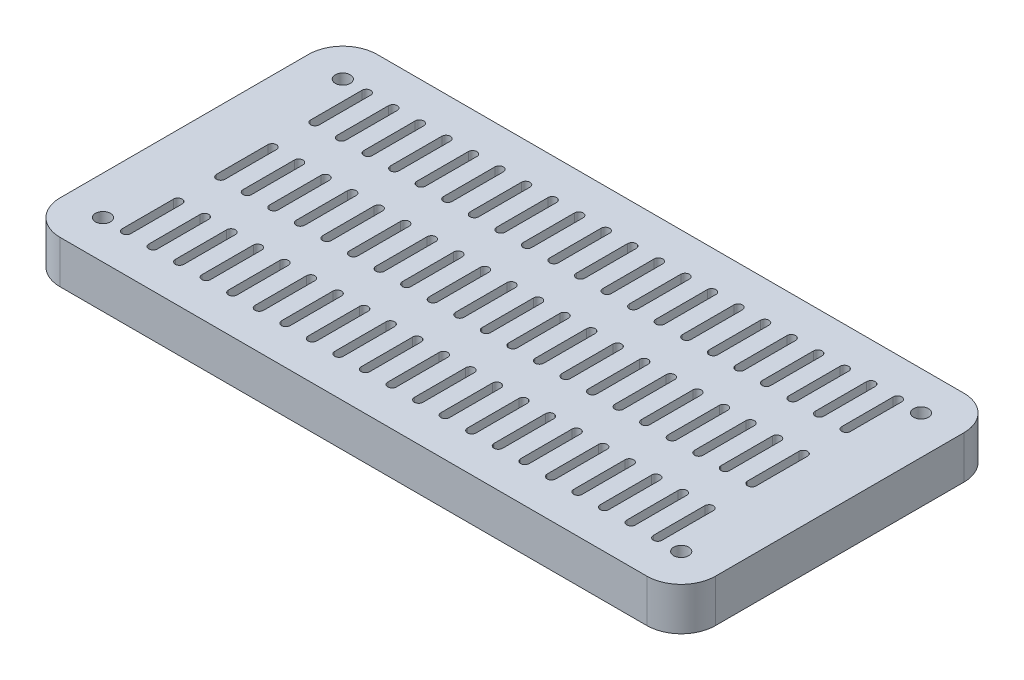
from build123d import *

# Parameters (mm, degrees)
SKETCH1_W               = 153
SKETCH1_H               = 74
BOSS_EXTRUDE1_DEPTH     = 10
CUT_EXTRUDE1_DEPTH      = 11
LPATTERN1_COUNT         = 11
LPATTERN1_PITCH         = 6.2
LPATTERN1_COUNT_DIR2    = 2
LPATTERN1_PITCH_DIR2    = 22
SKETCH3_R               = 1.75
CUT_EXTRUDE2_DEPTH      = 11
MIRROR1_COPY_1_DEPTH    = 11
MIRROR1_COPY_2_DEPTH    = 11
MIRROR1_COPY_3_DEPTH    = 11
MIRROR1_COPY_4_DEPTH    = 11
MIRROR1_COPY_5_DEPTH    = 11
MIRROR1_COPY_6_DEPTH    = 11
MIRROR1_COPY_7_DEPTH    = 11
MIRROR1_COPY_8_DEPTH    = 11
MIRROR1_COPY_9_DEPTH    = 11
MIRROR1_COPY_10_DEPTH   = 11
MIRROR1_COPY_11_DEPTH   = 11
MIRROR1_COPY_12_DEPTH   = 11
MIRROR1_COPY_13_DEPTH   = 11
MIRROR1_COPY_14_DEPTH   = 11
MIRROR1_COPY_15_DEPTH   = 11
MIRROR1_COPY_16_DEPTH   = 11
MIRROR1_COPY_17_DEPTH   = 11
MIRROR1_COPY_18_DEPTH   = 11
MIRROR1_COPY_19_DEPTH   = 11
MIRROR1_COPY_20_DEPTH   = 11
MIRROR1_COPY_21_DEPTH   = 11
MIRROR1_COPY_22_DEPTH   = 11
MIRROR2_COPY_1_SKETCH_R = 1.75
MIRROR2_COPY_1_DEPTH    = 11
MIRROR2_COPY_2_DEPTH    = 11
MIRROR2_COPY_3_DEPTH    = 11
MIRROR2_COPY_4_DEPTH    = 11
MIRROR2_COPY_5_DEPTH    = 11
MIRROR2_COPY_6_DEPTH    = 11
MIRROR2_COPY_7_DEPTH    = 11
MIRROR2_COPY_8_DEPTH    = 11
MIRROR2_COPY_9_DEPTH    = 11
MIRROR2_COPY_10_DEPTH   = 11
MIRROR2_COPY_11_DEPTH   = 11
MIRROR2_COPY_12_DEPTH   = 11
MIRROR2_COPY_13_DEPTH   = 11
MIRROR2_COPY_14_DEPTH   = 11
MIRROR2_COPY_15_DEPTH   = 11
MIRROR2_COPY_16_DEPTH   = 11
MIRROR2_COPY_17_DEPTH   = 11
MIRROR2_COPY_18_DEPTH   = 11
MIRROR2_COPY_19_DEPTH   = 11
MIRROR2_COPY_20_DEPTH   = 11
MIRROR2_COPY_21_DEPTH   = 11
MIRROR2_COPY_22_DEPTH   = 11
MIRROR2_COPY_23_DEPTH   = 11
MIRROR2_COPY_24_DEPTH   = 11
MIRROR2_COPY_25_DEPTH   = 11
MIRROR2_COPY_26_DEPTH   = 11
MIRROR2_COPY_27_DEPTH   = 11
MIRROR2_COPY_28_DEPTH   = 11
MIRROR2_COPY_29_DEPTH   = 11
MIRROR2_COPY_30_DEPTH   = 11
MIRROR2_COPY_31_DEPTH   = 11
MIRROR2_COPY_32_DEPTH   = 11
MIRROR2_COPY_33_DEPTH   = 11
MIRROR2_COPY_34_DEPTH   = 11
MIRROR2_COPY_35_DEPTH   = 11
MIRROR2_COPY_36_DEPTH   = 11
MIRROR2_COPY_37_DEPTH   = 11
MIRROR2_COPY_38_DEPTH   = 11
MIRROR2_COPY_39_DEPTH   = 11
MIRROR2_COPY_40_DEPTH   = 11
MIRROR2_COPY_41_DEPTH   = 11
MIRROR2_COPY_42_DEPTH   = 11
MIRROR2_COPY_43_DEPTH   = 11
MIRROR2_COPY_44_DEPTH   = 11
MIRROR2_COPY_45_DEPTH   = 11
MIRROR2_COPY_46_DEPTH   = 11
FILLET1_R               = 8


with BuildPart() as part:
    # Sketch1 → Boss-Extrude1 (new body)
    with BuildSketch(Plane(origin=(0, 0, 0), x_dir=(1, 0, 0), z_dir=(0, 1, 0))):
        Rectangle(SKETCH1_W, SKETCH1_H)
        with BuildLine():
            ThreePointArc((39.5, -27), (66.5, 0), (39.5, 27))
            Line((39.5, 27), (-39.5, 27))
            ThreePointArc((-39.5, 27), (-66.5, 0), (-39.5, -27))
            Line((-39.5, -27), (39.5, -27))
        make_face(mode=Mode.SUBTRACT)
        with BuildLine():
            Line((-39.5, -27), (39.5, -27))
            ThreePointArc((39.5, -27), (66.5, 0), (39.5, 27))
            Line((39.5, 27), (-39.5, 27))
            ThreePointArc((-39.5, 27), (-66.5, 0), (-39.5, -27))
        make_face()
        with BuildLine():
            ThreePointArc((1, 6), (0, 7), (-1, 6))
            Line((-1, 6), (-1, -6))
            ThreePointArc((-1, -6), (0, -7), (1, -6))
            Line((1, -6), (1, 6))
        make_face(mode=Mode.SUBTRACT)
        with BuildLine():
            Line((1, -6), (1, 6))
            ThreePointArc((1, 6), (0, 7), (-1, 6))
            Line((-1, 6), (-1, -6))
            ThreePointArc((-1, -6), (0, -7), (1, -6))
        make_face()
    extrude(amount=BOSS_EXTRUDE1_DEPTH)

    # Sketch1_3 → Cut-Extrude1 (cut, through all)
    with BuildSketch(Plane(origin=(0, 0, 0), x_dir=(1, 0, 0), z_dir=(0, 1, 0))):
        with BuildLine():
            Line((1, -6), (1, 6))
            ThreePointArc((1, 6), (0, 7), (-1, 6))
            Line((-1, 6), (-1, -6))
            ThreePointArc((-1, -6), (0, -7), (1, -6))
        make_face()
    cut_extrude1 = extrude(amount=CUT_EXTRUDE1_DEPTH, mode=Mode.SUBTRACT)

    # LPattern1: Cut-Extrude1 11 × 2
    with Locations(*[(i * LPATTERN1_PITCH, 0, -j * LPATTERN1_PITCH_DIR2) for i in range(LPATTERN1_COUNT) for j in range(LPATTERN1_COUNT_DIR2) if (i, j) != (0, 0)]):
        add(cut_extrude1, mode=Mode.SUBTRACT)

    # Sketch3 → Cut-Extrude2 (cut, through all)
    with BuildSketch(Plane(origin=(0, 10, 0), x_dir=(1, 0, 0), z_dir=(0, 1, 0))):
        with Locations((67.5, 28)):
            Circle(SKETCH3_R)
    cut_extrude2 = extrude(amount=-CUT_EXTRUDE2_DEPTH, mode=Mode.SUBTRACT)

    # Mirror1: Cut-Extrude2 across plane
    add(cut_extrude2.mirror(Plane(origin=(0, 0, 0), x_dir=(0, 0, 1), z_dir=(1, 0, 0))), mode=Mode.SUBTRACT)

    # Mirror1 copy 1 sketch → Mirror1 copy 1 (cut, through all)
    with BuildSketch(Plane(origin=(0, 0, -22), x_dir=(-1, 0, 0), z_dir=(0, 1, 0))):
        with BuildLine():
            Line((1, 6), (1, -6))
            ThreePointArc((1, -6), (0, -7), (-1, -6))
            Line((-1, -6), (-1, 6))
            ThreePointArc((-1, 6), (0, 7), (1, 6))
        make_face()
    extrude(amount=MIRROR1_COPY_1_DEPTH, mode=Mode.SUBTRACT)

    # Mirror1 copy 2 sketch → Mirror1 copy 2 (cut, through all)
    with BuildSketch(Plane(origin=(-6.2, 0, 0), x_dir=(-1, 0, 0), z_dir=(0, 1, 0))):
        with BuildLine():
            Line((1, 6), (1, -6))
            ThreePointArc((1, -6), (0, -7), (-1, -6))
            Line((-1, -6), (-1, 6))
            ThreePointArc((-1, 6), (0, 7), (1, 6))
        make_face()
    extrude(amount=MIRROR1_COPY_2_DEPTH, mode=Mode.SUBTRACT)

    # Mirror1 copy 3 sketch → Mirror1 copy 3 (cut, through all)
    with BuildSketch(Plane(origin=(-6.2, 0, -22), x_dir=(-1, 0, 0), z_dir=(0, 1, 0))):
        with BuildLine():
            Line((1, 6), (1, -6))
            ThreePointArc((1, -6), (0, -7), (-1, -6))
            Line((-1, -6), (-1, 6))
            ThreePointArc((-1, 6), (0, 7), (1, 6))
        make_face()
    extrude(amount=MIRROR1_COPY_3_DEPTH, mode=Mode.SUBTRACT)

    # Mirror1 copy 4 sketch → Mirror1 copy 4 (cut, through all)
    with BuildSketch(Plane(origin=(-12.4, 0, 0), x_dir=(-1, 0, 0), z_dir=(0, 1, 0))):
        with BuildLine():
            Line((1, 6), (1, -6))
            ThreePointArc((1, -6), (0, -7), (-1, -6))
            Line((-1, -6), (-1, 6))
            ThreePointArc((-1, 6), (0, 7), (1, 6))
        make_face()
    extrude(amount=MIRROR1_COPY_4_DEPTH, mode=Mode.SUBTRACT)

    # Mirror1 copy 5 sketch → Mirror1 copy 5 (cut, through all)
    with BuildSketch(Plane(origin=(-12.4, 0, -22), x_dir=(-1, 0, 0), z_dir=(0, 1, 0))):
        with BuildLine():
            Line((1, 6), (1, -6))
            ThreePointArc((1, -6), (0, -7), (-1, -6))
            Line((-1, -6), (-1, 6))
            ThreePointArc((-1, 6), (0, 7), (1, 6))
        make_face()
    extrude(amount=MIRROR1_COPY_5_DEPTH, mode=Mode.SUBTRACT)

    # Mirror1 copy 6 sketch → Mirror1 copy 6 (cut, through all)
    with BuildSketch(Plane(origin=(-18.6, 0, 0), x_dir=(-1, 0, 0), z_dir=(0, 1, 0))):
        with BuildLine():
            Line((1, 6), (1, -6))
            ThreePointArc((1, -6), (0, -7), (-1, -6))
            Line((-1, -6), (-1, 6))
            ThreePointArc((-1, 6), (0, 7), (1, 6))
        make_face()
    extrude(amount=MIRROR1_COPY_6_DEPTH, mode=Mode.SUBTRACT)

    # Mirror1 copy 7 sketch → Mirror1 copy 7 (cut, through all)
    with BuildSketch(Plane(origin=(-18.6, 0, -22), x_dir=(-1, 0, 0), z_dir=(0, 1, 0))):
        with BuildLine():
            Line((1, 6), (1, -6))
            ThreePointArc((1, -6), (0, -7), (-1, -6))
            Line((-1, -6), (-1, 6))
            ThreePointArc((-1, 6), (0, 7), (1, 6))
        make_face()
    extrude(amount=MIRROR1_COPY_7_DEPTH, mode=Mode.SUBTRACT)

    # Mirror1 copy 8 sketch → Mirror1 copy 8 (cut, through all)
    with BuildSketch(Plane(origin=(-24.8, 0, 0), x_dir=(-1, 0, 0), z_dir=(0, 1, 0))):
        with BuildLine():
            Line((1, 6), (1, -6))
            ThreePointArc((1, -6), (0, -7), (-1, -6))
            Line((-1, -6), (-1, 6))
            ThreePointArc((-1, 6), (0, 7), (1, 6))
        make_face()
    extrude(amount=MIRROR1_COPY_8_DEPTH, mode=Mode.SUBTRACT)

    # Mirror1 copy 9 sketch → Mirror1 copy 9 (cut, through all)
    with BuildSketch(Plane(origin=(-24.8, 0, -22), x_dir=(-1, 0, 0), z_dir=(0, 1, 0))):
        with BuildLine():
            Line((1, 6), (1, -6))
            ThreePointArc((1, -6), (0, -7), (-1, -6))
            Line((-1, -6), (-1, 6))
            ThreePointArc((-1, 6), (0, 7), (1, 6))
        make_face()
    extrude(amount=MIRROR1_COPY_9_DEPTH, mode=Mode.SUBTRACT)

    # Mirror1 copy 10 sketch → Mirror1 copy 10 (cut, through all)
    with BuildSketch(Plane(origin=(-31, 0, 0), x_dir=(-1, 0, 0), z_dir=(0, 1, 0))):
        with BuildLine():
            Line((1, 6), (1, -6))
            ThreePointArc((1, -6), (0, -7), (-1, -6))
            Line((-1, -6), (-1, 6))
            ThreePointArc((-1, 6), (0, 7), (1, 6))
        make_face()
    extrude(amount=MIRROR1_COPY_10_DEPTH, mode=Mode.SUBTRACT)

    # Mirror1 copy 11 sketch → Mirror1 copy 11 (cut, through all)
    with BuildSketch(Plane(origin=(-31, 0, -22), x_dir=(-1, 0, 0), z_dir=(0, 1, 0))):
        with BuildLine():
            Line((1, 6), (1, -6))
            ThreePointArc((1, -6), (0, -7), (-1, -6))
            Line((-1, -6), (-1, 6))
            ThreePointArc((-1, 6), (0, 7), (1, 6))
        make_face()
    extrude(amount=MIRROR1_COPY_11_DEPTH, mode=Mode.SUBTRACT)

    # Mirror1 copy 12 sketch → Mirror1 copy 12 (cut, through all)
    with BuildSketch(Plane(origin=(-37.2, 0, 0), x_dir=(-1, 0, 0), z_dir=(0, 1, 0))):
        with BuildLine():
            Line((1, 6), (1, -6))
            ThreePointArc((1, -6), (0, -7), (-1, -6))
            Line((-1, -6), (-1, 6))
            ThreePointArc((-1, 6), (0, 7), (1, 6))
        make_face()
    extrude(amount=MIRROR1_COPY_12_DEPTH, mode=Mode.SUBTRACT)

    # Mirror1 copy 13 sketch → Mirror1 copy 13 (cut, through all)
    with BuildSketch(Plane(origin=(-37.2, 0, -22), x_dir=(-1, 0, 0), z_dir=(0, 1, 0))):
        with BuildLine():
            Line((1, 6), (1, -6))
            ThreePointArc((1, -6), (0, -7), (-1, -6))
            Line((-1, -6), (-1, 6))
            ThreePointArc((-1, 6), (0, 7), (1, 6))
        make_face()
    extrude(amount=MIRROR1_COPY_13_DEPTH, mode=Mode.SUBTRACT)

    # Mirror1 copy 14 sketch → Mirror1 copy 14 (cut, through all)
    with BuildSketch(Plane(origin=(-43.4, 0, 0), x_dir=(-1, 0, 0), z_dir=(0, 1, 0))):
        with BuildLine():
            Line((1, 6), (1, -6))
            ThreePointArc((1, -6), (0, -7), (-1, -6))
            Line((-1, -6), (-1, 6))
            ThreePointArc((-1, 6), (0, 7), (1, 6))
        make_face()
    extrude(amount=MIRROR1_COPY_14_DEPTH, mode=Mode.SUBTRACT)

    # Mirror1 copy 15 sketch → Mirror1 copy 15 (cut, through all)
    with BuildSketch(Plane(origin=(-43.4, 0, -22), x_dir=(-1, 0, 0), z_dir=(0, 1, 0))):
        with BuildLine():
            Line((1, 6), (1, -6))
            ThreePointArc((1, -6), (0, -7), (-1, -6))
            Line((-1, -6), (-1, 6))
            ThreePointArc((-1, 6), (0, 7), (1, 6))
        make_face()
    extrude(amount=MIRROR1_COPY_15_DEPTH, mode=Mode.SUBTRACT)

    # Mirror1 copy 16 sketch → Mirror1 copy 16 (cut, through all)
    with BuildSketch(Plane(origin=(-49.6, 0, 0), x_dir=(-1, 0, 0), z_dir=(0, 1, 0))):
        with BuildLine():
            Line((1, 6), (1, -6))
            ThreePointArc((1, -6), (0, -7), (-1, -6))
            Line((-1, -6), (-1, 6))
            ThreePointArc((-1, 6), (0, 7), (1, 6))
        make_face()
    extrude(amount=MIRROR1_COPY_16_DEPTH, mode=Mode.SUBTRACT)

    # Mirror1 copy 17 sketch → Mirror1 copy 17 (cut, through all)
    with BuildSketch(Plane(origin=(-49.6, 0, -22), x_dir=(-1, 0, 0), z_dir=(0, 1, 0))):
        with BuildLine():
            Line((1, 6), (1, -6))
            ThreePointArc((1, -6), (0, -7), (-1, -6))
            Line((-1, -6), (-1, 6))
            ThreePointArc((-1, 6), (0, 7), (1, 6))
        make_face()
    extrude(amount=MIRROR1_COPY_17_DEPTH, mode=Mode.SUBTRACT)

    # Mirror1 copy 18 sketch → Mirror1 copy 18 (cut, through all)
    with BuildSketch(Plane(origin=(-55.8, 0, 0), x_dir=(-1, 0, 0), z_dir=(0, 1, 0))):
        with BuildLine():
            Line((1, 6), (1, -6))
            ThreePointArc((1, -6), (0, -7), (-1, -6))
            Line((-1, -6), (-1, 6))
            ThreePointArc((-1, 6), (0, 7), (1, 6))
        make_face()
    extrude(amount=MIRROR1_COPY_18_DEPTH, mode=Mode.SUBTRACT)

    # Mirror1 copy 19 sketch → Mirror1 copy 19 (cut, through all)
    with BuildSketch(Plane(origin=(-55.8, 0, -22), x_dir=(-1, 0, 0), z_dir=(0, 1, 0))):
        with BuildLine():
            Line((1, 6), (1, -6))
            ThreePointArc((1, -6), (0, -7), (-1, -6))
            Line((-1, -6), (-1, 6))
            ThreePointArc((-1, 6), (0, 7), (1, 6))
        make_face()
    extrude(amount=MIRROR1_COPY_19_DEPTH, mode=Mode.SUBTRACT)

    # Mirror1 copy 20 sketch → Mirror1 copy 20 (cut, through all)
    with BuildSketch(Plane(origin=(-62, 0, 0), x_dir=(-1, 0, 0), z_dir=(0, 1, 0))):
        with BuildLine():
            Line((1, 6), (1, -6))
            ThreePointArc((1, -6), (0, -7), (-1, -6))
            Line((-1, -6), (-1, 6))
            ThreePointArc((-1, 6), (0, 7), (1, 6))
        make_face()
    extrude(amount=MIRROR1_COPY_20_DEPTH, mode=Mode.SUBTRACT)

    # Mirror1 copy 21 sketch → Mirror1 copy 21 (cut, through all)
    with BuildSketch(Plane(origin=(-62, 0, -22), x_dir=(-1, 0, 0), z_dir=(0, 1, 0))):
        with BuildLine():
            Line((1, 6), (1, -6))
            ThreePointArc((1, -6), (0, -7), (-1, -6))
            Line((-1, -6), (-1, 6))
            ThreePointArc((-1, 6), (0, 7), (1, 6))
        make_face()
    extrude(amount=MIRROR1_COPY_21_DEPTH, mode=Mode.SUBTRACT)

    # Mirror1 copy 22 sketch → Mirror1 copy 22 (cut, through all)
    with BuildSketch(Plane(origin=(0, 0, 0), x_dir=(-1, 0, 0), z_dir=(0, 1, 0))):
        with BuildLine():
            Line((1, 6), (1, -6))
            ThreePointArc((1, -6), (0, -7), (-1, -6))
            Line((-1, -6), (-1, 6))
            ThreePointArc((-1, 6), (0, 7), (1, 6))
        make_face()
    extrude(amount=MIRROR1_COPY_22_DEPTH, mode=Mode.SUBTRACT)

    # Mirror2: Cut-Extrude2 across plane
    add(cut_extrude2.mirror(Plane.XY), mode=Mode.SUBTRACT)

    # Mirror2 copy 1 sketch → Mirror2 copy 1 (cut, through all)
    with BuildSketch(Plane(origin=(0, 10, 0), x_dir=(-1, 0, 0), z_dir=(0, 1, 0))):
        with Locations((67.5, 28)):
            Circle(MIRROR2_COPY_1_SKETCH_R)
    extrude(amount=-MIRROR2_COPY_1_DEPTH, mode=Mode.SUBTRACT)

    # Mirror2 copy 2 sketch → Mirror2 copy 2 (cut, through all)
    with BuildSketch(Plane(origin=(0, 0, 22), x_dir=(-1, 0, 0), z_dir=(0, 1, 0))):
        with BuildLine():
            Line((1, -6), (1, 6))
            ThreePointArc((1, 6), (0, 7), (-1, 6))
            Line((-1, 6), (-1, -6))
            ThreePointArc((-1, -6), (0, -7), (1, -6))
        make_face()
    extrude(amount=MIRROR2_COPY_2_DEPTH, mode=Mode.SUBTRACT)

    # Mirror2 copy 3 sketch → Mirror2 copy 3 (cut, through all)
    with BuildSketch(Plane(origin=(-6.2, 0, 0), x_dir=(-1, 0, 0), z_dir=(0, 1, 0))):
        with BuildLine():
            Line((1, -6), (1, 6))
            ThreePointArc((1, 6), (0, 7), (-1, 6))
            Line((-1, 6), (-1, -6))
            ThreePointArc((-1, -6), (0, -7), (1, -6))
        make_face()
    extrude(amount=MIRROR2_COPY_3_DEPTH, mode=Mode.SUBTRACT)

    # Mirror2 copy 4 sketch → Mirror2 copy 4 (cut, through all)
    with BuildSketch(Plane(origin=(-6.2, 0, 22), x_dir=(-1, 0, 0), z_dir=(0, 1, 0))):
        with BuildLine():
            Line((1, -6), (1, 6))
            ThreePointArc((1, 6), (0, 7), (-1, 6))
            Line((-1, 6), (-1, -6))
            ThreePointArc((-1, -6), (0, -7), (1, -6))
        make_face()
    extrude(amount=MIRROR2_COPY_4_DEPTH, mode=Mode.SUBTRACT)

    # Mirror2 copy 5 sketch → Mirror2 copy 5 (cut, through all)
    with BuildSketch(Plane(origin=(-12.4, 0, 0), x_dir=(-1, 0, 0), z_dir=(0, 1, 0))):
        with BuildLine():
            Line((1, -6), (1, 6))
            ThreePointArc((1, 6), (0, 7), (-1, 6))
            Line((-1, 6), (-1, -6))
            ThreePointArc((-1, -6), (0, -7), (1, -6))
        make_face()
    extrude(amount=MIRROR2_COPY_5_DEPTH, mode=Mode.SUBTRACT)

    # Mirror2 copy 6 sketch → Mirror2 copy 6 (cut, through all)
    with BuildSketch(Plane(origin=(-12.4, 0, 22), x_dir=(-1, 0, 0), z_dir=(0, 1, 0))):
        with BuildLine():
            Line((1, -6), (1, 6))
            ThreePointArc((1, 6), (0, 7), (-1, 6))
            Line((-1, 6), (-1, -6))
            ThreePointArc((-1, -6), (0, -7), (1, -6))
        make_face()
    extrude(amount=MIRROR2_COPY_6_DEPTH, mode=Mode.SUBTRACT)

    # Mirror2 copy 7 sketch → Mirror2 copy 7 (cut, through all)
    with BuildSketch(Plane(origin=(-18.6, 0, 0), x_dir=(-1, 0, 0), z_dir=(0, 1, 0))):
        with BuildLine():
            Line((1, -6), (1, 6))
            ThreePointArc((1, 6), (0, 7), (-1, 6))
            Line((-1, 6), (-1, -6))
            ThreePointArc((-1, -6), (0, -7), (1, -6))
        make_face()
    extrude(amount=MIRROR2_COPY_7_DEPTH, mode=Mode.SUBTRACT)

    # Mirror2 copy 8 sketch → Mirror2 copy 8 (cut, through all)
    with BuildSketch(Plane(origin=(-18.6, 0, 22), x_dir=(-1, 0, 0), z_dir=(0, 1, 0))):
        with BuildLine():
            Line((1, -6), (1, 6))
            ThreePointArc((1, 6), (0, 7), (-1, 6))
            Line((-1, 6), (-1, -6))
            ThreePointArc((-1, -6), (0, -7), (1, -6))
        make_face()
    extrude(amount=MIRROR2_COPY_8_DEPTH, mode=Mode.SUBTRACT)

    # Mirror2 copy 9 sketch → Mirror2 copy 9 (cut, through all)
    with BuildSketch(Plane(origin=(-24.8, 0, 0), x_dir=(-1, 0, 0), z_dir=(0, 1, 0))):
        with BuildLine():
            Line((1, -6), (1, 6))
            ThreePointArc((1, 6), (0, 7), (-1, 6))
            Line((-1, 6), (-1, -6))
            ThreePointArc((-1, -6), (0, -7), (1, -6))
        make_face()
    extrude(amount=MIRROR2_COPY_9_DEPTH, mode=Mode.SUBTRACT)

    # Mirror2 copy 10 sketch → Mirror2 copy 10 (cut, through all)
    with BuildSketch(Plane(origin=(-24.8, 0, 22), x_dir=(-1, 0, 0), z_dir=(0, 1, 0))):
        with BuildLine():
            Line((1, -6), (1, 6))
            ThreePointArc((1, 6), (0, 7), (-1, 6))
            Line((-1, 6), (-1, -6))
            ThreePointArc((-1, -6), (0, -7), (1, -6))
        make_face()
    extrude(amount=MIRROR2_COPY_10_DEPTH, mode=Mode.SUBTRACT)

    # Mirror2 copy 11 sketch → Mirror2 copy 11 (cut, through all)
    with BuildSketch(Plane(origin=(-31, 0, 0), x_dir=(-1, 0, 0), z_dir=(0, 1, 0))):
        with BuildLine():
            Line((1, -6), (1, 6))
            ThreePointArc((1, 6), (0, 7), (-1, 6))
            Line((-1, 6), (-1, -6))
            ThreePointArc((-1, -6), (0, -7), (1, -6))
        make_face()
    extrude(amount=MIRROR2_COPY_11_DEPTH, mode=Mode.SUBTRACT)

    # Mirror2 copy 12 sketch → Mirror2 copy 12 (cut, through all)
    with BuildSketch(Plane(origin=(-31, 0, 22), x_dir=(-1, 0, 0), z_dir=(0, 1, 0))):
        with BuildLine():
            Line((1, -6), (1, 6))
            ThreePointArc((1, 6), (0, 7), (-1, 6))
            Line((-1, 6), (-1, -6))
            ThreePointArc((-1, -6), (0, -7), (1, -6))
        make_face()
    extrude(amount=MIRROR2_COPY_12_DEPTH, mode=Mode.SUBTRACT)

    # Mirror2 copy 13 sketch → Mirror2 copy 13 (cut, through all)
    with BuildSketch(Plane(origin=(-37.2, 0, 0), x_dir=(-1, 0, 0), z_dir=(0, 1, 0))):
        with BuildLine():
            Line((1, -6), (1, 6))
            ThreePointArc((1, 6), (0, 7), (-1, 6))
            Line((-1, 6), (-1, -6))
            ThreePointArc((-1, -6), (0, -7), (1, -6))
        make_face()
    extrude(amount=MIRROR2_COPY_13_DEPTH, mode=Mode.SUBTRACT)

    # Mirror2 copy 14 sketch → Mirror2 copy 14 (cut, through all)
    with BuildSketch(Plane(origin=(-37.2, 0, 22), x_dir=(-1, 0, 0), z_dir=(0, 1, 0))):
        with BuildLine():
            Line((1, -6), (1, 6))
            ThreePointArc((1, 6), (0, 7), (-1, 6))
            Line((-1, 6), (-1, -6))
            ThreePointArc((-1, -6), (0, -7), (1, -6))
        make_face()
    extrude(amount=MIRROR2_COPY_14_DEPTH, mode=Mode.SUBTRACT)

    # Mirror2 copy 15 sketch → Mirror2 copy 15 (cut, through all)
    with BuildSketch(Plane(origin=(-43.4, 0, 0), x_dir=(-1, 0, 0), z_dir=(0, 1, 0))):
        with BuildLine():
            Line((1, -6), (1, 6))
            ThreePointArc((1, 6), (0, 7), (-1, 6))
            Line((-1, 6), (-1, -6))
            ThreePointArc((-1, -6), (0, -7), (1, -6))
        make_face()
    extrude(amount=MIRROR2_COPY_15_DEPTH, mode=Mode.SUBTRACT)

    # Mirror2 copy 16 sketch → Mirror2 copy 16 (cut, through all)
    with BuildSketch(Plane(origin=(-43.4, 0, 22), x_dir=(-1, 0, 0), z_dir=(0, 1, 0))):
        with BuildLine():
            Line((1, -6), (1, 6))
            ThreePointArc((1, 6), (0, 7), (-1, 6))
            Line((-1, 6), (-1, -6))
            ThreePointArc((-1, -6), (0, -7), (1, -6))
        make_face()
    extrude(amount=MIRROR2_COPY_16_DEPTH, mode=Mode.SUBTRACT)

    # Mirror2 copy 17 sketch → Mirror2 copy 17 (cut, through all)
    with BuildSketch(Plane(origin=(-49.6, 0, 0), x_dir=(-1, 0, 0), z_dir=(0, 1, 0))):
        with BuildLine():
            Line((1, -6), (1, 6))
            ThreePointArc((1, 6), (0, 7), (-1, 6))
            Line((-1, 6), (-1, -6))
            ThreePointArc((-1, -6), (0, -7), (1, -6))
        make_face()
    extrude(amount=MIRROR2_COPY_17_DEPTH, mode=Mode.SUBTRACT)

    # Mirror2 copy 18 sketch → Mirror2 copy 18 (cut, through all)
    with BuildSketch(Plane(origin=(-49.6, 0, 22), x_dir=(-1, 0, 0), z_dir=(0, 1, 0))):
        with BuildLine():
            Line((1, -6), (1, 6))
            ThreePointArc((1, 6), (0, 7), (-1, 6))
            Line((-1, 6), (-1, -6))
            ThreePointArc((-1, -6), (0, -7), (1, -6))
        make_face()
    extrude(amount=MIRROR2_COPY_18_DEPTH, mode=Mode.SUBTRACT)

    # Mirror2 copy 19 sketch → Mirror2 copy 19 (cut, through all)
    with BuildSketch(Plane(origin=(-55.8, 0, 0), x_dir=(-1, 0, 0), z_dir=(0, 1, 0))):
        with BuildLine():
            Line((1, -6), (1, 6))
            ThreePointArc((1, 6), (0, 7), (-1, 6))
            Line((-1, 6), (-1, -6))
            ThreePointArc((-1, -6), (0, -7), (1, -6))
        make_face()
    extrude(amount=MIRROR2_COPY_19_DEPTH, mode=Mode.SUBTRACT)

    # Mirror2 copy 20 sketch → Mirror2 copy 20 (cut, through all)
    with BuildSketch(Plane(origin=(-55.8, 0, 22), x_dir=(-1, 0, 0), z_dir=(0, 1, 0))):
        with BuildLine():
            Line((1, -6), (1, 6))
            ThreePointArc((1, 6), (0, 7), (-1, 6))
            Line((-1, 6), (-1, -6))
            ThreePointArc((-1, -6), (0, -7), (1, -6))
        make_face()
    extrude(amount=MIRROR2_COPY_20_DEPTH, mode=Mode.SUBTRACT)

    # Mirror2 copy 21 sketch → Mirror2 copy 21 (cut, through all)
    with BuildSketch(Plane(origin=(-62, 0, 0), x_dir=(-1, 0, 0), z_dir=(0, 1, 0))):
        with BuildLine():
            Line((1, -6), (1, 6))
            ThreePointArc((1, 6), (0, 7), (-1, 6))
            Line((-1, 6), (-1, -6))
            ThreePointArc((-1, -6), (0, -7), (1, -6))
        make_face()
    extrude(amount=MIRROR2_COPY_21_DEPTH, mode=Mode.SUBTRACT)

    # Mirror2 copy 22 sketch → Mirror2 copy 22 (cut, through all)
    with BuildSketch(Plane(origin=(-62, 0, 22), x_dir=(-1, 0, 0), z_dir=(0, 1, 0))):
        with BuildLine():
            Line((1, -6), (1, 6))
            ThreePointArc((1, 6), (0, 7), (-1, 6))
            Line((-1, 6), (-1, -6))
            ThreePointArc((-1, -6), (0, -7), (1, -6))
        make_face()
    extrude(amount=MIRROR2_COPY_22_DEPTH, mode=Mode.SUBTRACT)

    # Mirror2 copy 23 sketch → Mirror2 copy 23 (cut, through all)
    with BuildSketch(Plane(origin=(0, 0, 0), x_dir=(-1, 0, 0), z_dir=(0, 1, 0))):
        with BuildLine():
            Line((1, -6), (1, 6))
            ThreePointArc((1, 6), (0, 7), (-1, 6))
            Line((-1, 6), (-1, -6))
            ThreePointArc((-1, -6), (0, -7), (1, -6))
        make_face()
    extrude(amount=MIRROR2_COPY_23_DEPTH, mode=Mode.SUBTRACT)

    # Mirror2 copy 24 sketch → Mirror2 copy 24 (cut, through all)
    with BuildSketch(Plane(origin=(0, 0, 0), x_dir=(1, 0, 0), z_dir=(0, 1, 0))):
        with BuildLine():
            Line((1, 6), (1, -6))
            ThreePointArc((1, -6), (0, -7), (-1, -6))
            Line((-1, -6), (-1, 6))
            ThreePointArc((-1, 6), (0, 7), (1, 6))
        make_face()
    extrude(amount=MIRROR2_COPY_24_DEPTH, mode=Mode.SUBTRACT)

    # Mirror2 copy 25 sketch → Mirror2 copy 25 (cut, through all)
    with BuildSketch(Plane(origin=(0, 0, 22), x_dir=(1, 0, 0), z_dir=(0, 1, 0))):
        with BuildLine():
            Line((1, 6), (1, -6))
            ThreePointArc((1, -6), (0, -7), (-1, -6))
            Line((-1, -6), (-1, 6))
            ThreePointArc((-1, 6), (0, 7), (1, 6))
        make_face()
    extrude(amount=MIRROR2_COPY_25_DEPTH, mode=Mode.SUBTRACT)

    # Mirror2 copy 26 sketch → Mirror2 copy 26 (cut, through all)
    with BuildSketch(Plane(origin=(6.2, 0, 0), x_dir=(1, 0, 0), z_dir=(0, 1, 0))):
        with BuildLine():
            Line((1, 6), (1, -6))
            ThreePointArc((1, -6), (0, -7), (-1, -6))
            Line((-1, -6), (-1, 6))
            ThreePointArc((-1, 6), (0, 7), (1, 6))
        make_face()
    extrude(amount=MIRROR2_COPY_26_DEPTH, mode=Mode.SUBTRACT)

    # Mirror2 copy 27 sketch → Mirror2 copy 27 (cut, through all)
    with BuildSketch(Plane(origin=(6.2, 0, 22), x_dir=(1, 0, 0), z_dir=(0, 1, 0))):
        with BuildLine():
            Line((1, 6), (1, -6))
            ThreePointArc((1, -6), (0, -7), (-1, -6))
            Line((-1, -6), (-1, 6))
            ThreePointArc((-1, 6), (0, 7), (1, 6))
        make_face()
    extrude(amount=MIRROR2_COPY_27_DEPTH, mode=Mode.SUBTRACT)

    # Mirror2 copy 28 sketch → Mirror2 copy 28 (cut, through all)
    with BuildSketch(Plane(origin=(12.4, 0, 0), x_dir=(1, 0, 0), z_dir=(0, 1, 0))):
        with BuildLine():
            Line((1, 6), (1, -6))
            ThreePointArc((1, -6), (0, -7), (-1, -6))
            Line((-1, -6), (-1, 6))
            ThreePointArc((-1, 6), (0, 7), (1, 6))
        make_face()
    extrude(amount=MIRROR2_COPY_28_DEPTH, mode=Mode.SUBTRACT)

    # Mirror2 copy 29 sketch → Mirror2 copy 29 (cut, through all)
    with BuildSketch(Plane(origin=(12.4, 0, 22), x_dir=(1, 0, 0), z_dir=(0, 1, 0))):
        with BuildLine():
            Line((1, 6), (1, -6))
            ThreePointArc((1, -6), (0, -7), (-1, -6))
            Line((-1, -6), (-1, 6))
            ThreePointArc((-1, 6), (0, 7), (1, 6))
        make_face()
    extrude(amount=MIRROR2_COPY_29_DEPTH, mode=Mode.SUBTRACT)

    # Mirror2 copy 30 sketch → Mirror2 copy 30 (cut, through all)
    with BuildSketch(Plane(origin=(18.6, 0, 0), x_dir=(1, 0, 0), z_dir=(0, 1, 0))):
        with BuildLine():
            Line((1, 6), (1, -6))
            ThreePointArc((1, -6), (0, -7), (-1, -6))
            Line((-1, -6), (-1, 6))
            ThreePointArc((-1, 6), (0, 7), (1, 6))
        make_face()
    extrude(amount=MIRROR2_COPY_30_DEPTH, mode=Mode.SUBTRACT)

    # Mirror2 copy 31 sketch → Mirror2 copy 31 (cut, through all)
    with BuildSketch(Plane(origin=(18.6, 0, 22), x_dir=(1, 0, 0), z_dir=(0, 1, 0))):
        with BuildLine():
            Line((1, 6), (1, -6))
            ThreePointArc((1, -6), (0, -7), (-1, -6))
            Line((-1, -6), (-1, 6))
            ThreePointArc((-1, 6), (0, 7), (1, 6))
        make_face()
    extrude(amount=MIRROR2_COPY_31_DEPTH, mode=Mode.SUBTRACT)

    # Mirror2 copy 32 sketch → Mirror2 copy 32 (cut, through all)
    with BuildSketch(Plane(origin=(24.8, 0, 0), x_dir=(1, 0, 0), z_dir=(0, 1, 0))):
        with BuildLine():
            Line((1, 6), (1, -6))
            ThreePointArc((1, -6), (0, -7), (-1, -6))
            Line((-1, -6), (-1, 6))
            ThreePointArc((-1, 6), (0, 7), (1, 6))
        make_face()
    extrude(amount=MIRROR2_COPY_32_DEPTH, mode=Mode.SUBTRACT)

    # Mirror2 copy 33 sketch → Mirror2 copy 33 (cut, through all)
    with BuildSketch(Plane(origin=(24.8, 0, 22), x_dir=(1, 0, 0), z_dir=(0, 1, 0))):
        with BuildLine():
            Line((1, 6), (1, -6))
            ThreePointArc((1, -6), (0, -7), (-1, -6))
            Line((-1, -6), (-1, 6))
            ThreePointArc((-1, 6), (0, 7), (1, 6))
        make_face()
    extrude(amount=MIRROR2_COPY_33_DEPTH, mode=Mode.SUBTRACT)

    # Mirror2 copy 34 sketch → Mirror2 copy 34 (cut, through all)
    with BuildSketch(Plane(origin=(31, 0, 0), x_dir=(1, 0, 0), z_dir=(0, 1, 0))):
        with BuildLine():
            Line((1, 6), (1, -6))
            ThreePointArc((1, -6), (0, -7), (-1, -6))
            Line((-1, -6), (-1, 6))
            ThreePointArc((-1, 6), (0, 7), (1, 6))
        make_face()
    extrude(amount=MIRROR2_COPY_34_DEPTH, mode=Mode.SUBTRACT)

    # Mirror2 copy 35 sketch → Mirror2 copy 35 (cut, through all)
    with BuildSketch(Plane(origin=(31, 0, 22), x_dir=(1, 0, 0), z_dir=(0, 1, 0))):
        with BuildLine():
            Line((1, 6), (1, -6))
            ThreePointArc((1, -6), (0, -7), (-1, -6))
            Line((-1, -6), (-1, 6))
            ThreePointArc((-1, 6), (0, 7), (1, 6))
        make_face()
    extrude(amount=MIRROR2_COPY_35_DEPTH, mode=Mode.SUBTRACT)

    # Mirror2 copy 36 sketch → Mirror2 copy 36 (cut, through all)
    with BuildSketch(Plane(origin=(37.2, 0, 0), x_dir=(1, 0, 0), z_dir=(0, 1, 0))):
        with BuildLine():
            Line((1, 6), (1, -6))
            ThreePointArc((1, -6), (0, -7), (-1, -6))
            Line((-1, -6), (-1, 6))
            ThreePointArc((-1, 6), (0, 7), (1, 6))
        make_face()
    extrude(amount=MIRROR2_COPY_36_DEPTH, mode=Mode.SUBTRACT)

    # Mirror2 copy 37 sketch → Mirror2 copy 37 (cut, through all)
    with BuildSketch(Plane(origin=(37.2, 0, 22), x_dir=(1, 0, 0), z_dir=(0, 1, 0))):
        with BuildLine():
            Line((1, 6), (1, -6))
            ThreePointArc((1, -6), (0, -7), (-1, -6))
            Line((-1, -6), (-1, 6))
            ThreePointArc((-1, 6), (0, 7), (1, 6))
        make_face()
    extrude(amount=MIRROR2_COPY_37_DEPTH, mode=Mode.SUBTRACT)

    # Mirror2 copy 38 sketch → Mirror2 copy 38 (cut, through all)
    with BuildSketch(Plane(origin=(43.4, 0, 0), x_dir=(1, 0, 0), z_dir=(0, 1, 0))):
        with BuildLine():
            Line((1, 6), (1, -6))
            ThreePointArc((1, -6), (0, -7), (-1, -6))
            Line((-1, -6), (-1, 6))
            ThreePointArc((-1, 6), (0, 7), (1, 6))
        make_face()
    extrude(amount=MIRROR2_COPY_38_DEPTH, mode=Mode.SUBTRACT)

    # Mirror2 copy 39 sketch → Mirror2 copy 39 (cut, through all)
    with BuildSketch(Plane(origin=(43.4, 0, 22), x_dir=(1, 0, 0), z_dir=(0, 1, 0))):
        with BuildLine():
            Line((1, 6), (1, -6))
            ThreePointArc((1, -6), (0, -7), (-1, -6))
            Line((-1, -6), (-1, 6))
            ThreePointArc((-1, 6), (0, 7), (1, 6))
        make_face()
    extrude(amount=MIRROR2_COPY_39_DEPTH, mode=Mode.SUBTRACT)

    # Mirror2 copy 40 sketch → Mirror2 copy 40 (cut, through all)
    with BuildSketch(Plane(origin=(49.6, 0, 0), x_dir=(1, 0, 0), z_dir=(0, 1, 0))):
        with BuildLine():
            Line((1, 6), (1, -6))
            ThreePointArc((1, -6), (0, -7), (-1, -6))
            Line((-1, -6), (-1, 6))
            ThreePointArc((-1, 6), (0, 7), (1, 6))
        make_face()
    extrude(amount=MIRROR2_COPY_40_DEPTH, mode=Mode.SUBTRACT)

    # Mirror2 copy 41 sketch → Mirror2 copy 41 (cut, through all)
    with BuildSketch(Plane(origin=(49.6, 0, 22), x_dir=(1, 0, 0), z_dir=(0, 1, 0))):
        with BuildLine():
            Line((1, 6), (1, -6))
            ThreePointArc((1, -6), (0, -7), (-1, -6))
            Line((-1, -6), (-1, 6))
            ThreePointArc((-1, 6), (0, 7), (1, 6))
        make_face()
    extrude(amount=MIRROR2_COPY_41_DEPTH, mode=Mode.SUBTRACT)

    # Mirror2 copy 42 sketch → Mirror2 copy 42 (cut, through all)
    with BuildSketch(Plane(origin=(55.8, 0, 0), x_dir=(1, 0, 0), z_dir=(0, 1, 0))):
        with BuildLine():
            Line((1, 6), (1, -6))
            ThreePointArc((1, -6), (0, -7), (-1, -6))
            Line((-1, -6), (-1, 6))
            ThreePointArc((-1, 6), (0, 7), (1, 6))
        make_face()
    extrude(amount=MIRROR2_COPY_42_DEPTH, mode=Mode.SUBTRACT)

    # Mirror2 copy 43 sketch → Mirror2 copy 43 (cut, through all)
    with BuildSketch(Plane(origin=(55.8, 0, 22), x_dir=(1, 0, 0), z_dir=(0, 1, 0))):
        with BuildLine():
            Line((1, 6), (1, -6))
            ThreePointArc((1, -6), (0, -7), (-1, -6))
            Line((-1, -6), (-1, 6))
            ThreePointArc((-1, 6), (0, 7), (1, 6))
        make_face()
    extrude(amount=MIRROR2_COPY_43_DEPTH, mode=Mode.SUBTRACT)

    # Mirror2 copy 44 sketch → Mirror2 copy 44 (cut, through all)
    with BuildSketch(Plane(origin=(62, 0, 0), x_dir=(1, 0, 0), z_dir=(0, 1, 0))):
        with BuildLine():
            Line((1, 6), (1, -6))
            ThreePointArc((1, -6), (0, -7), (-1, -6))
            Line((-1, -6), (-1, 6))
            ThreePointArc((-1, 6), (0, 7), (1, 6))
        make_face()
    extrude(amount=MIRROR2_COPY_44_DEPTH, mode=Mode.SUBTRACT)

    # Mirror2 copy 45 sketch → Mirror2 copy 45 (cut, through all)
    with BuildSketch(Plane(origin=(62, 0, 22), x_dir=(1, 0, 0), z_dir=(0, 1, 0))):
        with BuildLine():
            Line((1, 6), (1, -6))
            ThreePointArc((1, -6), (0, -7), (-1, -6))
            Line((-1, -6), (-1, 6))
            ThreePointArc((-1, 6), (0, 7), (1, 6))
        make_face()
    extrude(amount=MIRROR2_COPY_45_DEPTH, mode=Mode.SUBTRACT)

    # Mirror2 copy 46 sketch → Mirror2 copy 46 (cut, through all)
    with BuildSketch(Plane(origin=(0, 0, 0), x_dir=(1, 0, 0), z_dir=(0, 1, 0))):
        with BuildLine():
            Line((1, 6), (1, -6))
            ThreePointArc((1, -6), (0, -7), (-1, -6))
            Line((-1, -6), (-1, 6))
            ThreePointArc((-1, 6), (0, 7), (1, 6))
        make_face()
    extrude(amount=MIRROR2_COPY_46_DEPTH, mode=Mode.SUBTRACT)

    # Fillet1
    fillet1_edges = [part.edges().sort_by_distance(p)[0] for p in [
        (-76.5, 5, 37),
        (-76.5, 5, -37),
        (76.5, 5, -37),
        (76.5, 5, 37),
    ]]
    fillet(fillet1_edges, radius=FILLET1_R)


solid = part.part
